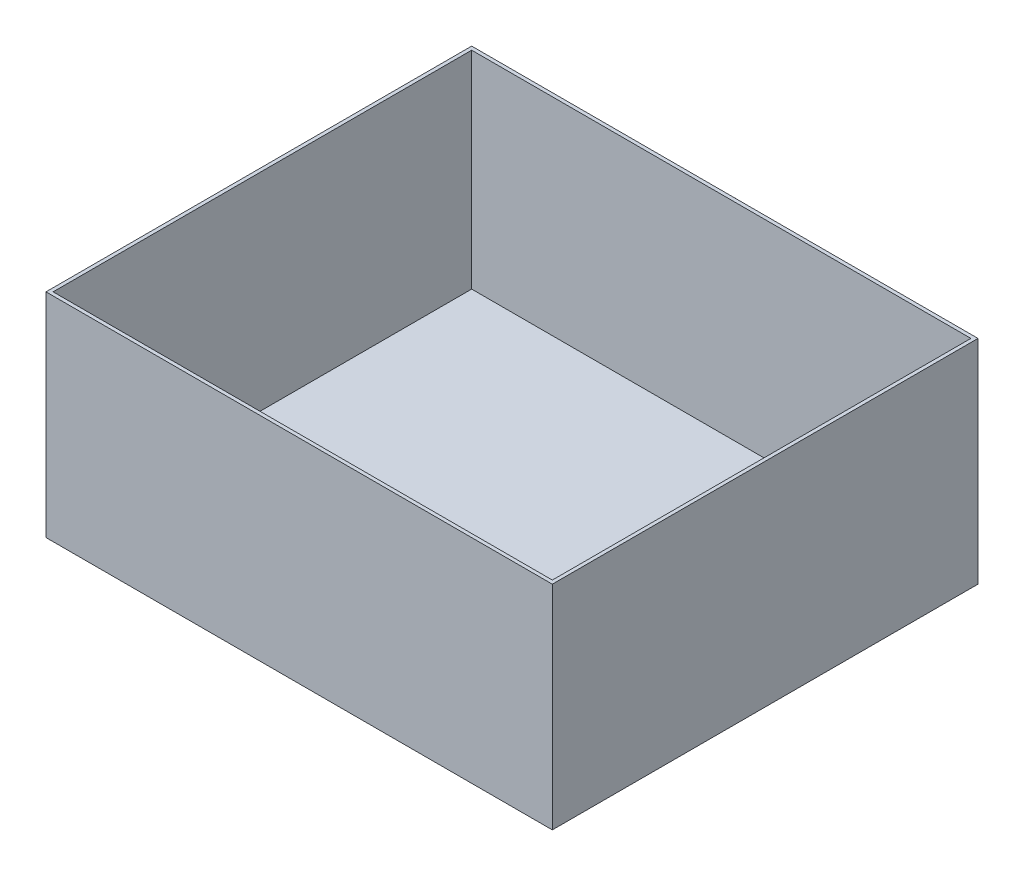
from build123d import *

# Parameters (mm, degrees)
SKETCH1_W           = 214.105532568
SKETCH1_H           = 180
BOSS_EXTRUDE1_DEPTH = 90
SKETCH2_W           = 211.105532568
SKETCH2_H           = 177
CUT_EXTRUDE1_DEPTH  = 87.5


with BuildPart() as part:
    # Sketch1 → Boss-Extrude1 (new body)
    with BuildSketch(Plane(origin=(0, 0, 0), x_dir=(1, 0, 0), z_dir=(0, 1, 0))):
        with Locations((107.052766284, 90)):
            Rectangle(SKETCH1_W, SKETCH1_H)
    extrude(amount=BOSS_EXTRUDE1_DEPTH)

    # Sketch2 → Cut-Extrude1 (cut)
    with BuildSketch(Plane(origin=(0, 90, 0), x_dir=(1, 0, 0), z_dir=(0, 1, 0))):
        with Locations((107.052766284, 90)):
            Rectangle(SKETCH2_W, SKETCH2_H)
    extrude(amount=-CUT_EXTRUDE1_DEPTH, mode=Mode.SUBTRACT)


solid = part.part
